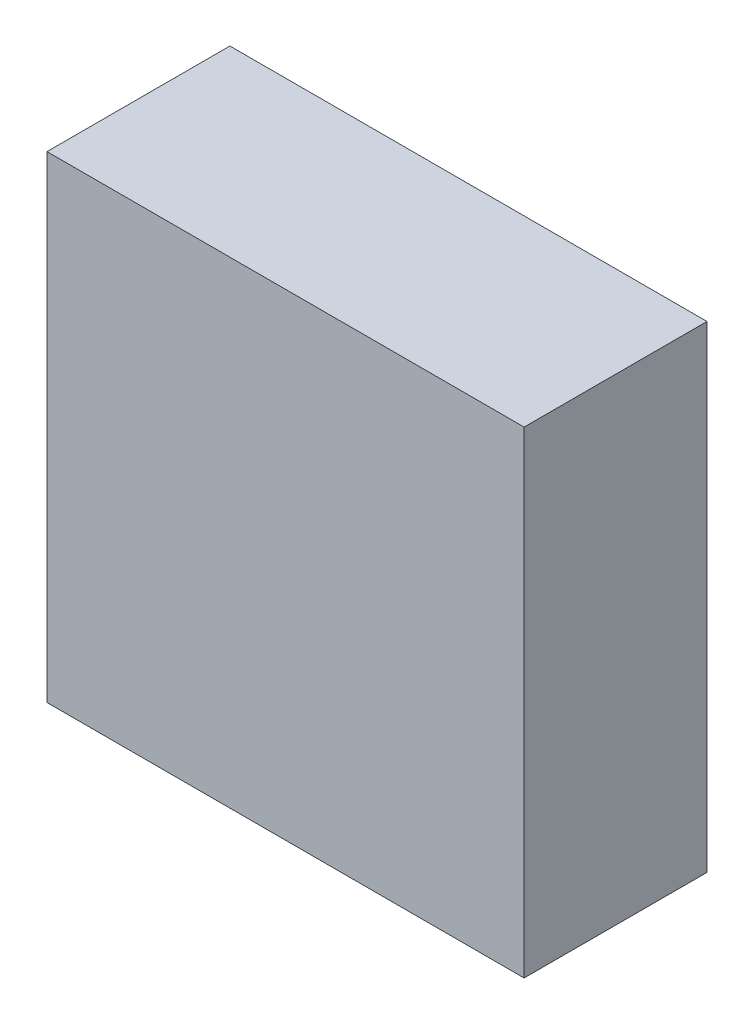
from build123d import *

# Parameters (mm, degrees)
SKETCH_1_W      = 6
SKETCH_1_H      = 6
EXTRUDE_1_DEPTH = 2.3


with BuildPart() as part:
    # 草图1 → 凸台-拉伸1 (new body)
    with BuildSketch(Plane.XY):
        with Locations((20.249587155, 12.312648367)):
            Rectangle(SKETCH_1_W, SKETCH_1_H)
    extrude(amount=EXTRUDE_1_DEPTH)


solid = part.part
